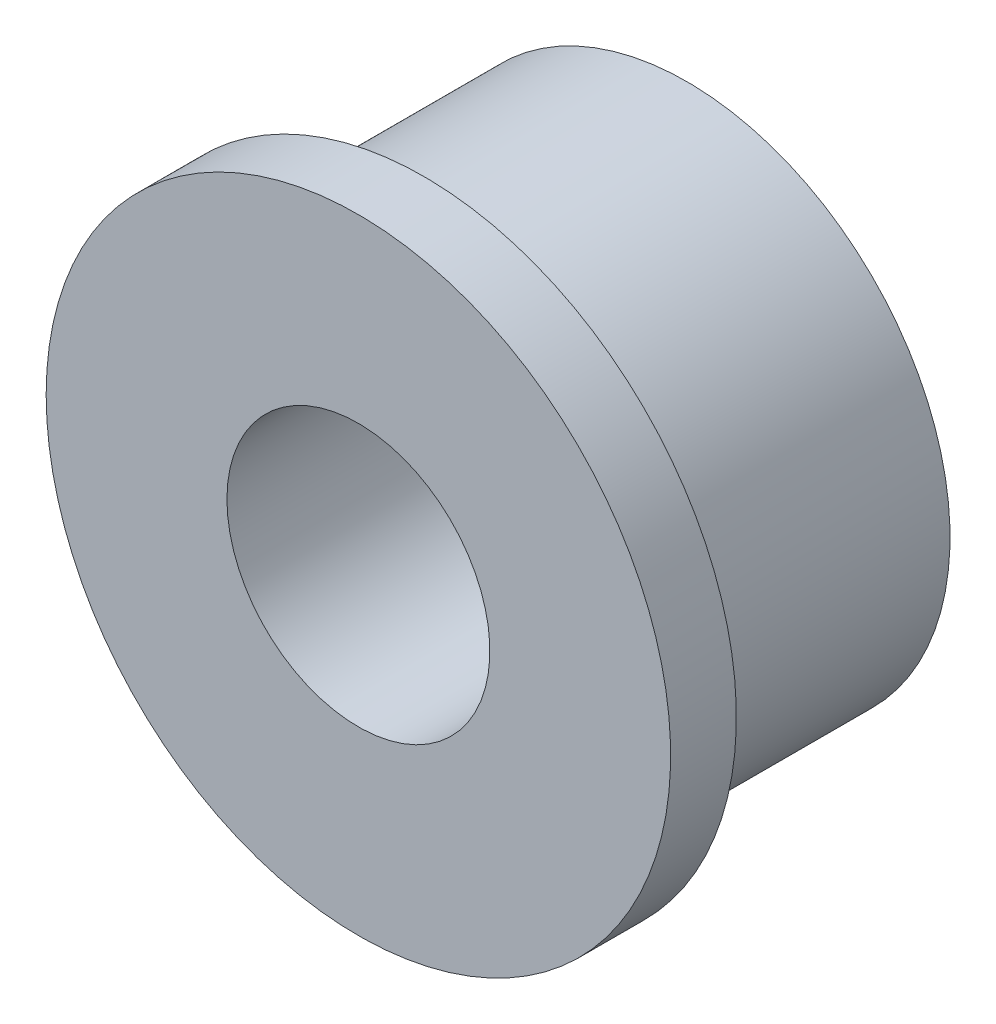
from build123d import *

# Parameters (mm, degrees)
SKETCH_1_W = 5.5
SKETCH_1_H = 2


with BuildPart() as part:
    # Эскиз1 → Повернуть1 (revolve)
    with BuildSketch(Plane(origin=(0, 0, 0), x_dir=(1, 0, 0), z_dir=(0, 1, 0))):
        Polygon((0, 7.199169847), (0, 2), (4, 2), (4, 10), align=None)
        with Locations((2.75, 1)):
            Rectangle(SKETCH_1_W, SKETCH_1_H)
    revolve(axis=Axis((-4, 0, -5.527093596), (0, 0, 1)))


solid = part.part
